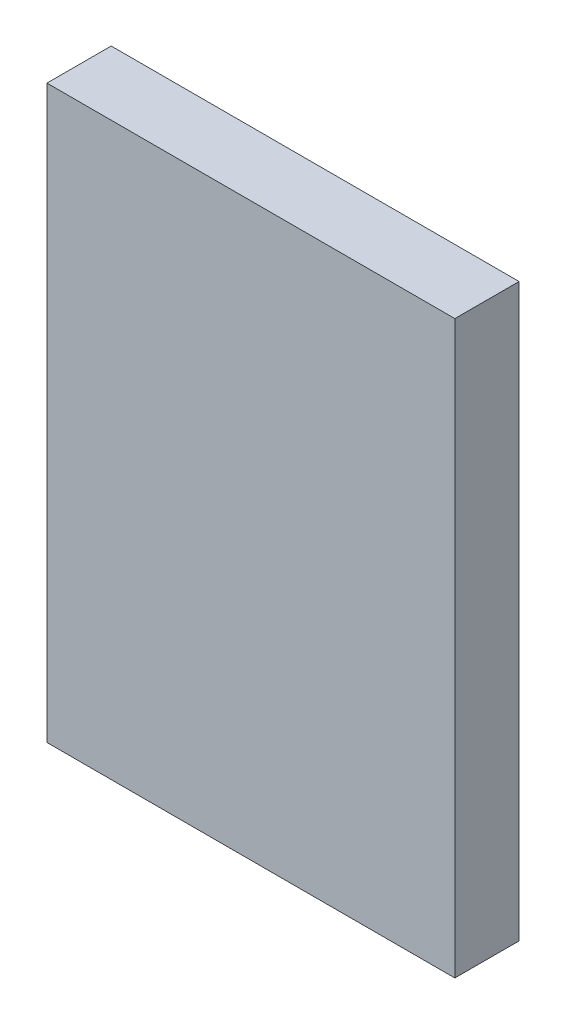
from build123d import *

# Parameters (mm, degrees)
SKETCH1_W               = 6.35
SKETCH1_H               = 8.89
COMPONENT_OUTLINE_DEPTH = 1


with BuildPart() as part:
    # Sketch1 → Component_Outline (new body)
    with BuildSketch(Plane.XY):
        Rectangle(SKETCH1_W, SKETCH1_H)
    extrude(amount=COMPONENT_OUTLINE_DEPTH)


solid = part.part
